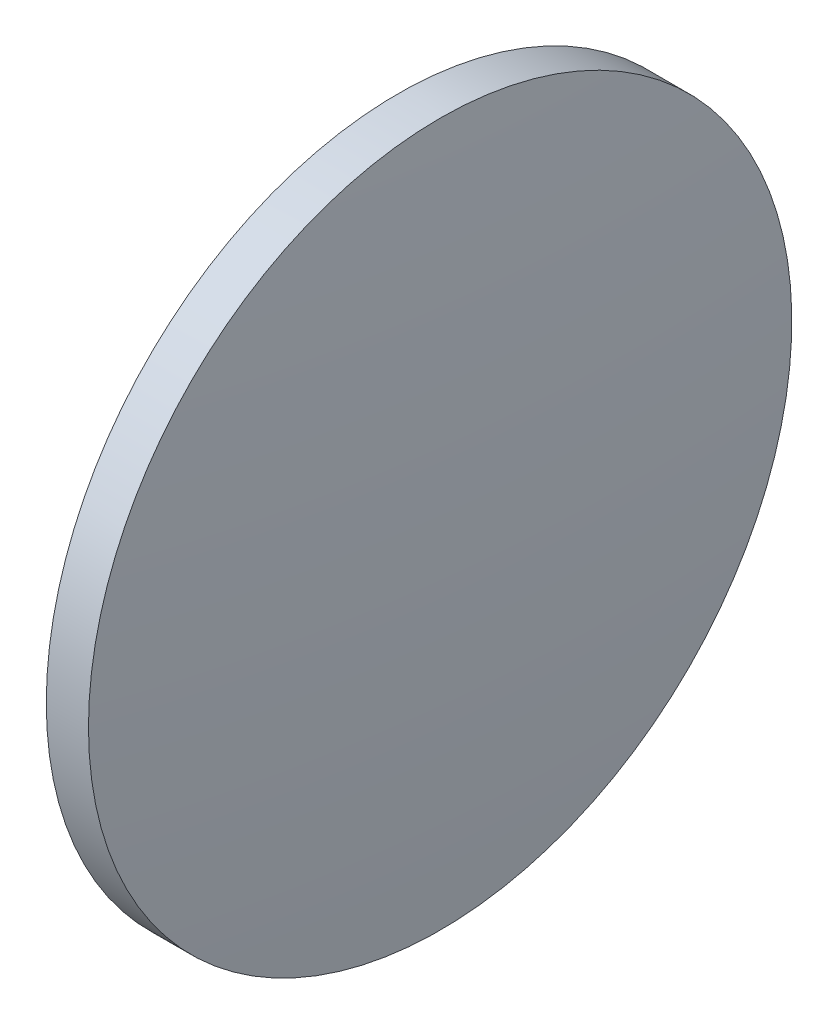
from build123d import *


with BuildPart() as part:
    # 草图1 → 旋转1 (revolve)
    with BuildSketch(Plane.XY):
        with BuildLine():
            Line((492.979271375, 143.858480456), (492.979271375, 156.358480456))
            Line((492.979271375, 156.358480456), (494.479271375, 156.358480456))
            ThreePointArc((494.479271375, 156.358480456), (494.854221415, 150.113478457), (494.979271375, 143.858480456))
            Line((494.979271375, 143.858480456), (492.979271375, 143.858480456))
        make_face()
    revolve(axis=Axis((490.613655472, 143.858480456, 0), (1, 0, 0)))


solid = part.part
